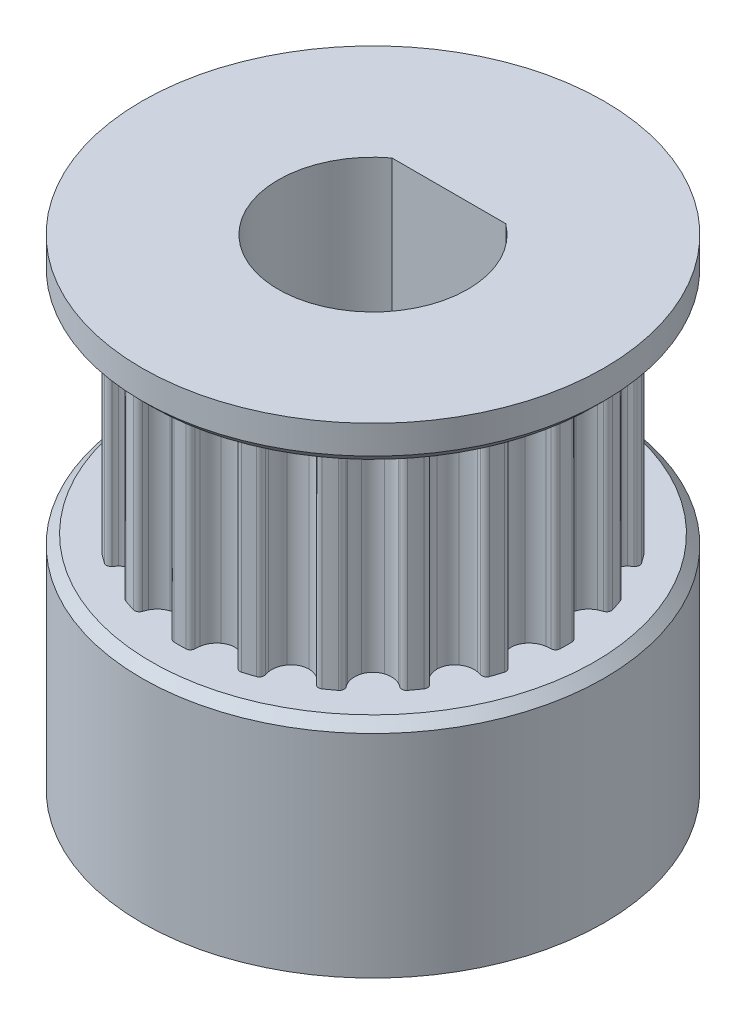
from build123d import *

# Parameters (mm, degrees)
BOSS_EXTRUDE1_DEPTH = 7
SKETCH2_R           = 5.362197724
BOSS_EXTRUDE2_DEPTH = 7
CIRPATTERN3_COUNT   = 20
SKETCH3_R           = 7.312197724
BOSS_EXTRUDE3_DEPTH = 1.2
SKETCH4_R           = 7.312197724
BOSS_EXTRUDE4_DEPTH = 7
CUT_EXTRUDE1_DEPTH  = 16.2
CHAMFER1_SIZE       = 0.3


with BuildPart() as part:
    # Sketch1 → Boss-Extrude1 (new body)
    with BuildSketch(Plane(origin=(0, 0, 0), x_dir=(1, 0, 0), z_dir=(0, 1, 0))):
        with BuildLine():
            ThreePointArc((-0.838832532, 5.296180172), (-0.708843717, 5.333447554), (-0.591725856, 5.401044571))
            ThreePointArc((-0.591725856, 5.401044571), (-0.427411064, 5.584158965), (-0.344526118, 5.815805934))
            ThreePointArc((-0.344526118, 5.815805934), (-0.336322126, 5.887755805), (-0.333346558, 5.960110732))
            ThreePointArc((-0.333346558, 5.960110732), (-0.290777478, 6.064063067), (-0.187961119, 6.109306968))
            ThreePointArc((-0.187961119, 6.109306968), (0, 6.112197724), (0.187961119, 6.109306968))
            ThreePointArc((0.187961119, 6.109306968), (0.290777478, 6.064063067), (0.333346558, 5.960110732))
            ThreePointArc((0.333346558, 5.960110732), (0.336322126, 5.887755805), (0.344526118, 5.815805934))
            ThreePointArc((0.344526118, 5.815805934), (0.427411064, 5.584158965), (0.591725856, 5.401044571))
            ThreePointArc((0.591725856, 5.401044571), (0.708843717, 5.333447554), (0.838832532, 5.296180172))
            ThreePointArc((0.838832532, 5.296180172), (0, 5.362197724), (-0.838832532, 5.296180172))
        make_face()
    boss_extrude1 = extrude(amount=BOSS_EXTRUDE1_DEPTH)

    # Sketch2 → Boss-Extrude2 (add)
    with BuildSketch(Plane.XZ):
        Circle(SKETCH2_R)
        with BuildLine():
            ThreePointArc((-0.838832532, -5.296180172), (-0.708843717, -5.333447554), (-0.591725856, -5.401044571))
            ThreePointArc((-0.591725856, -5.401044571), (-0.427411064, -5.584158965), (-0.344526118, -5.815805934))
            ThreePointArc((-0.344526118, -5.815805934), (-0.336322126, -5.887755805), (-0.333346558, -5.960110732))
            ThreePointArc((-0.333346558, -5.960110732), (-0.290777478, -6.064063067), (-0.187961119, -6.109306968))
            ThreePointArc((-0.187961119, -6.109306968), (0, -6.112197724), (0.187961119, -6.109306968))
            ThreePointArc((0.187961119, -6.109306968), (0.290777478, -6.064063067), (0.333346558, -5.960110732))
            ThreePointArc((0.333346558, -5.960110732), (0.336322126, -5.887755805), (0.344526118, -5.815805934))
            ThreePointArc((0.344526118, -5.815805934), (0.427411064, -5.584158965), (0.591725856, -5.401044571))
            ThreePointArc((0.591725856, -5.401044571), (0.708843717, -5.333447554), (0.838832532, -5.296180172))
            ThreePointArc((0.838832532, -5.296180172), (0, -5.362197724), (-0.838832532, -5.296180172))
        make_face()
    extrude(amount=-BOSS_EXTRUDE2_DEPTH)

    # CirPattern3: Boss-Extrude1 ×20 about axis
    cirpattern3_axis = Axis((0, 0, 0), (0, 1, 0))
    for i in range(1, CIRPATTERN3_COUNT):
        add(boss_extrude1.rotate(cirpattern3_axis, i * 360 / CIRPATTERN3_COUNT))

    # Sketch3 → Boss-Extrude3 (add)
    with BuildSketch(Plane(origin=(0, 7, 0), x_dir=(1, 0, 0), z_dir=(0, 1, 0))):
        Circle(SKETCH3_R)
    extrude(amount=BOSS_EXTRUDE3_DEPTH)

    # Sketch4 → Boss-Extrude4 (add)
    with BuildSketch(Plane.XZ):
        Circle(SKETCH4_R)
    extrude(amount=BOSS_EXTRUDE4_DEPTH)

    # Sketch5 → Cut-Extrude1 (cut, through all)
    with BuildSketch(Plane(origin=(0, 8.2, 0), x_dir=(1, 0, 0), z_dir=(0, 1, 0))):
        with BuildLine():
            Line((1.8, 2.4), (-1.8, 2.4))
            ThreePointArc((-1.8, 2.4), (0, -3), (1.8, 2.4))
        make_face()
    extrude(amount=-CUT_EXTRUDE1_DEPTH, mode=Mode.SUBTRACT)

    # Chamfer1
    chamfer1_edges = [part.edges().sort_by_distance(p)[0] for p in [
        (-7.312197724, 7, 0),
        (-7.312197724, 0, 0),
    ]]
    chamfer(chamfer1_edges, length=CHAMFER1_SIZE)


solid = part.part
